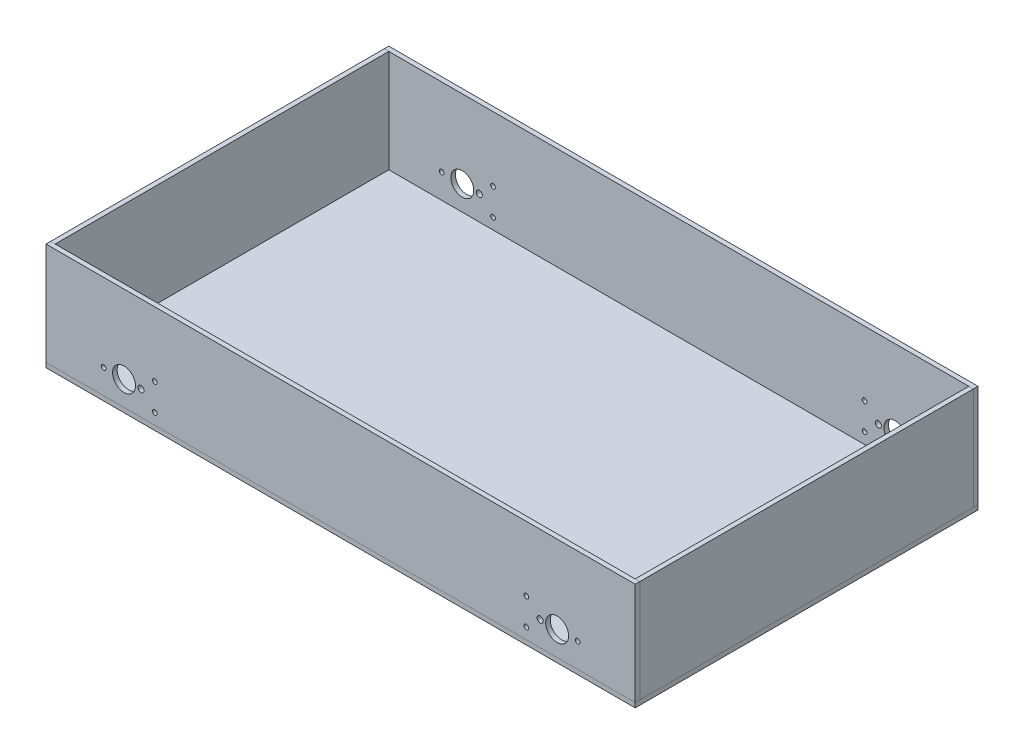
from build123d import *

# Parameters (mm, degrees)
CROQUIS1_W                = 385
CROQUIS1_H                = 224
SALIENTE_EXTRUIR1_DEPTH   = 3
CROQUIS3_W                = 385
CROQUIS3_H                = 3
SALIENTE_EXTRUIR2_DEPTH   = 67
SALIENTE_EXTRUIR2_2_DEPTH = 67
CROQUIS4_W                = 3
CROQUIS4_H                = 218
SALIENTE_EXTRUIR3_DEPTH   = 67
SALIENTE_EXTRUIR3_2_DEPTH = 67
CROQUIS5_R                = 7.5
CROQUIS5_R_2              = 1.55
CROQUIS5_R_3              = 2
CORTAR_EXTRUIR1_DEPTH     = 224


with BuildPart() as part:
    # Croquis1 → Saliente-Extruir1 (new body)
    with BuildSketch(Plane(origin=(0, 0, 0), x_dir=(1, 0, 0), z_dir=(0, 1, 0))):
        Rectangle(CROQUIS1_W, CROQUIS1_H)
    extrude(amount=SALIENTE_EXTRUIR1_DEPTH)


with BuildPart() as body_2:
    # Croquis3 → Saliente-Extruir2 (new body)
    with BuildSketch(Plane(origin=(0, 3, 0), x_dir=(1, 0, 0), z_dir=(0, 1, 0))):
        with Locations((0, 110.5)):
            Rectangle(CROQUIS3_W, CROQUIS3_H)
    extrude(amount=SALIENTE_EXTRUIR2_DEPTH)


with BuildPart() as body_3:
    # Croquis3 → Saliente-Extruir2 2 (new body)
    with BuildSketch(Plane(origin=(0, 3, 0), x_dir=(1, 0, 0), z_dir=(0, 1, 0))):
        with Locations((0, -110.5)):
            Rectangle(CROQUIS3_W, CROQUIS3_H)
    extrude(amount=SALIENTE_EXTRUIR2_2_DEPTH)


with BuildPart() as body_4:
    # Croquis4 → Saliente-Extruir3 (new body)
    with BuildSketch(Plane(origin=(0, 3, 0), x_dir=(1, 0, 0), z_dir=(0, 1, 0))):
        with Locations((-191, 0)):
            Rectangle(CROQUIS4_W, CROQUIS4_H)
    extrude(amount=SALIENTE_EXTRUIR3_DEPTH)


with BuildPart() as body_5:
    # Croquis4 → Saliente-Extruir3 2 (new body)
    with BuildSketch(Plane(origin=(0, 3, 0), x_dir=(1, 0, 0), z_dir=(0, 1, 0))):
        with Locations((191, 0)):
            Rectangle(CROQUIS4_W, CROQUIS4_H)
    extrude(amount=SALIENTE_EXTRUIR3_2_DEPTH)


with BuildPart() as cortar_extruir1_tool:
    # Croquis5 → Cortar-Extruir1 (new body)
    with BuildSketch(Plane.XY.offset(112)):
        with Locations((-141.5, 19)):
            Circle(CROQUIS5_R)
        with Locations((141.5, 19)):
            Circle(CROQUIS5_R)
        with Locations((-121.4, 27.75)):
            Circle(CROQUIS5_R_2)
        with Locations((-121.4, 10.25)):
            Circle(CROQUIS5_R_2)
        with Locations((-154.9, 19)):
            Circle(CROQUIS5_R_2)
        with Locations((121.4, 27.75)):
            Circle(CROQUIS5_R_2)
        with Locations((121.4, 10.25)):
            Circle(CROQUIS5_R_2)
        with Locations((154.9, 19)):
            Circle(CROQUIS5_R_2)
        with Locations((-130.4, 19)):
            Circle(CROQUIS5_R_3)
        with Locations((130.4, 19)):
            Circle(CROQUIS5_R_3)
    extrude(amount=-CORTAR_EXTRUIR1_DEPTH)


with BuildPart() as body_2_1:
    add(body_2.part)

    # Cortar-Extruir1: cut by cortar_extruir1_tool
    add(cortar_extruir1_tool.part, mode=Mode.SUBTRACT)


with BuildPart() as body_3_1:
    add(body_3.part)

    # Cortar-Extruir1: cut by cortar_extruir1_tool
    add(cortar_extruir1_tool.part, mode=Mode.SUBTRACT)


solid = Compound([part.part, body_4.part, body_5.part, body_2_1.part, body_3_1.part])
